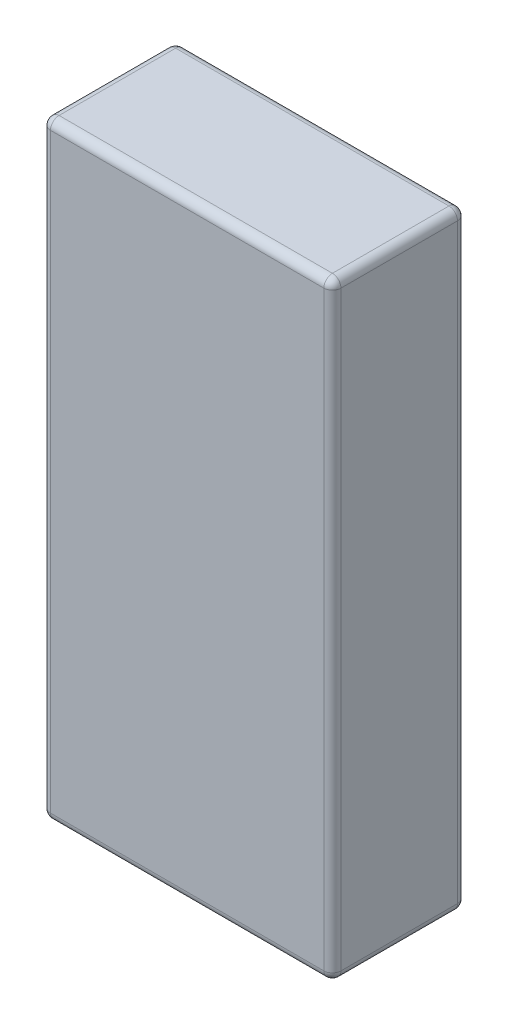
from build123d import *

# Parameters (mm, degrees)
SKETCH1_W           = 33.9
SKETCH1_H           = 71
BOSS_EXTRUDE1_DEPTH = 7.8
FILLET1_R           = 1
FILLET2_R           = 1


with BuildPart() as part:
    # Sketch1 → Boss-Extrude1 (new, symmetric)
    with BuildSketch(Plane.XY):
        Rectangle(SKETCH1_W, SKETCH1_H)
    extrude(amount=BOSS_EXTRUDE1_DEPTH, both=True)

    # Fillet1
    fillet1_edges = [part.edges().sort_by_distance(p)[0] for p in [
        (0, -35.5, -7.8),
        (0, -35.5, 7.8),
        (0, 35.5, -7.8),
        (0, 35.5, 7.8),
    ]]
    fillet(fillet1_edges, radius=FILLET1_R)

    # Fillet2
    fillet2_edges = [part.edges().sort_by_distance(p)[0] for p in [
        (-16.95, 35.207106781, 7.507106781),
        (-16.95, 35.5, 0),
        (-16.95, 35.207106781, -7.507106781),
        (-16.95, 0, -7.8),
        (-16.95, -35.207106781, -7.507106781),
        (-16.95, -35.5, 0),
        (-16.95, -35.207106781, 7.507106781),
        (16.95, -35.207106781, 7.507106781),
        (16.95, 0, 7.8),
        (16.95, 35.207106781, 7.507106781),
        (16.95, 35.5, 0),
        (16.95, 35.207106781, -7.507106781),
        (16.95, 0, -7.8),
        (16.95, -35.207106781, -7.507106781),
        (16.95, -35.5, 0),
        (-16.95, 0, 7.8),
    ]]
    fillet(fillet2_edges, radius=FILLET2_R)


solid = part.part
